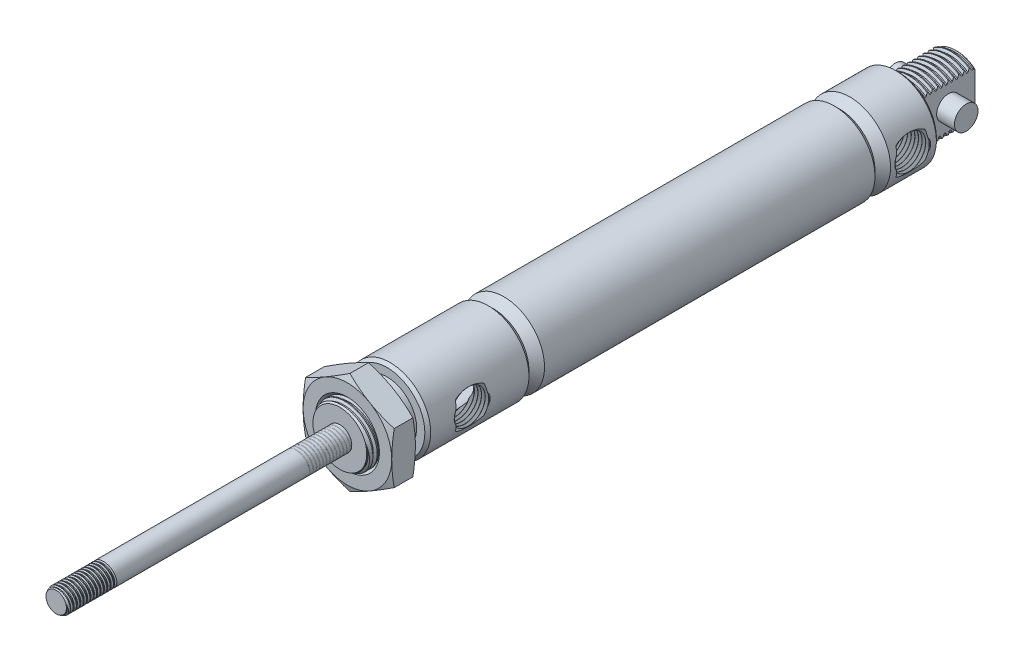
from build123d import *
from build123d.topology import SkipClean

# Parameters (mm, degrees)
SKETCH1_W            = 153.162
SKETCH1_H            = 10.922
SKETCH58_W           = 15.748
SKETCH58_H           = 2.9845
SKETCH59_OUTSIDE_W   = 55.094
SKETCH59_OUTSIDE_H   = 55.094
SKETCH59_OUTSIDE_W_2 = 9.525
SKETCH59_OUTSIDE_H_2 = 15.875
CUT_EXTRUDE3_DEPTH   = 15.748
CHAMFER1_SIZE        = 0.7874
SKETCH4_W            = 12.7
SKETCH4_H            = 7.9375
LPATTERN2_COUNT      = 2
LPATTERN2_PITCH      = 1.411111224
LPATTERN2_COL_COUNT  = 9
LPATTERN2_COL_PITCH  = 1.411111224
SKETCH53_W           = 2.286
SKETCH53_H           = 7.9375
LPATTERN5_COUNT      = 11
LPATTERN5_PITCH      = 1.411111224
SKETCH60_R           = 3.175
EXTRUDE2_DEPTH       = 9.525
LPATTERN3_COUNT      = 2
LPATTERN3_PITCH      = 0.907142966
LPATTERN3_COL_COUNT  = 14
LPATTERN3_COL_PITCH  = 0.907142966
LPATTERN4_COUNT      = 2
LPATTERN4_PITCH      = 63.5
SKETCH54_R           = 7.9375
EXTRUDE1_DEPTH       = 3.175


with BuildPart() as part:
    # Sketch1 → Revolve1 (revolve)
    with BuildSketch(Plane(origin=(0, 0, 0), x_dir=(0, 0, -1), z_dir=(1, 0, 0)), mode=Mode.PRIVATE) as revolve1_sk:
        with Locations((12.7, 5.461)):
            Rectangle(SKETCH1_W, SKETCH1_H)
    revolve(revolve1_sk.sketch.rotate(Axis((0, 0, -89.281), (0, 0, -1)), 270), axis=Axis((0, 0, -89.281), (0, 0, -1)))

    # Sketch58 → Cut-Revolve25 (revolve, cut)
    with BuildSketch(Plane(origin=(0, 0, 0), x_dir=(0, 0, -1), z_dir=(1, 0, 0)), mode=Mode.PRIVATE) as cut_revolve25_sk:
        with Locations((81.407, 9.42975)):
            Rectangle(SKETCH58_W, SKETCH58_H)
    revolve(cut_revolve25_sk.sketch.rotate(Axis((0, 0, -89.281), (0, 0, -1)), 270), axis=Axis((0, 0, -89.281), (0, 0, -1)), mode=Mode.SUBTRACT)

    # Sketch59 outside → Cut-Extrude3 (cut)
    with BuildSketch(Plane(origin=(0, 0, -89.281), x_dir=(-1, 0, 0), z_dir=(0, 0, -1))):
        Rectangle(SKETCH59_OUTSIDE_W, SKETCH59_OUTSIDE_H)
        Rectangle(SKETCH59_OUTSIDE_W_2, SKETCH59_OUTSIDE_H_2, mode=Mode.SUBTRACT)
    extrude(amount=-CUT_EXTRUDE3_DEPTH, mode=Mode.SUBTRACT)

    # Chamfer1
    chamfer1_edges = [part.edges().sort_by_distance(p)[0] for p in [
        (0, -7.9375, -89.281),
        (10.922, 0, 63.881),
        (10.922, 0, -73.533),
        (0, 7.9375, -89.281),
    ]]
    chamfer(chamfer1_edges, length=CHAMFER1_SIZE)



with BuildPart() as body_2:
    # Sketch4 → Revolve2 (revolve)
    with BuildSketch(Plane(origin=(0, 0, 0), x_dir=(0, 0, -1), z_dir=(1, 0, 0)), mode=Mode.PRIVATE) as revolve2_sk:
        with Locations((-70.231, 3.96875)):
            Rectangle(SKETCH4_W, SKETCH4_H)
    revolve(revolve2_sk.sketch.rotate(Axis((0, 0, 76.581), (0, 0, -1)), 90), axis=Axis((0, 0, 76.581), (0, 0, -1)))

    # Sketch5 → Cut-Revolve2 (revolve, cut)
    with BuildSketch(Plane(origin=(0, 0, 0), x_dir=(0, 0, -1), z_dir=(1, 0, 0)), mode=Mode.PRIVATE) as cut_revolve2_sk:
        Polygon((-76.40530384, 7.953117438), (-75.175430718, 8.062439502), (-75.547045629, 7.262609217), (-75.89843795, 7.231374341), align=None)
    cut_revolve2 = revolve(cut_revolve2_sk.sketch.rotate(Axis((0, -0.133549816, 76.581), (0, 0.08853979731145159, -0.9960726400680059)), 180), axis=Axis((0, -0.133549816, 76.581), (0, 0.08853979731145159, -0.9960726400680059)), mode=Mode.SUBTRACT)

    # Sketch6 → Cut-Revolve3 (revolve, cut)
    with BuildSketch(Plane(origin=(0, 0, 0), x_dir=(0, 0, -1), z_dir=(1, 0, 0)), mode=Mode.PRIVATE) as cut_revolve3_sk:
        Polygon((-76.581, 7.231374341), (-75.357954482, 7.9375), (-76.581, 7.9375), align=None)
    revolve(cut_revolve3_sk.sketch.rotate(Axis((0, 0, 0), (0, 0, 1)), 270), axis=Axis((0, 0, 0), (0, 0, 1)), mode=Mode.SUBTRACT)

    # LPattern2: Cut-Revolve2 ×2
    with Locations(*[(0, 0, i * LPATTERN2_PITCH) for i in range(1, LPATTERN2_COUNT)]):
        add(cut_revolve2, mode=Mode.SUBTRACT)

    # LPattern2 col: Cut-Revolve2 ×9
    with Locations(*[(0, 0, -i * LPATTERN2_COL_PITCH) for i in range(1, LPATTERN2_COL_COUNT)]):
        add(cut_revolve2, mode=Mode.SUBTRACT)


with BuildPart() as part_1:
    with SkipClean():  # the faces are left unmerged after this step: merging them gives an invalid solid
        add(part.part)

        add(body_2.part)  # Revolve4 merges body 2
        # Sketch53 → Revolve4 (revolve)
        with BuildSketch(Plane(origin=(0, 0, 0), x_dir=(0, 0, -1), z_dir=(1, 0, 0)), mode=Mode.PRIVATE) as revolve4_sk:
            with Locations((-65.024, 3.96875)):
                Rectangle(SKETCH53_W, SKETCH53_H)
        revolve(revolve4_sk.sketch.rotate(Axis((0, 0, 63.881), (0, 0, 1)), 125.383849969), axis=Axis((0, 0, 63.881), (0, 0, 1)))

    # Sketch62 → Cut-Revolve26 (revolve, cut)
    with SkipClean():  # the faces are left unmerged after this step: merging them gives an invalid solid
        with BuildSketch(Plane(origin=(0, 0, 0), x_dir=(0, 0, -1), z_dir=(1, 0, 0))):
            Polygon((73.70869616, 7.953117438), (74.938569282, 8.062439502), (74.566954371, 7.262609217), (74.21556205, 7.231374341), align=None)
        cut_revolve26 = revolve(axis=Axis((0, -0.133549816, -73.533), (0, 0.08853979731145115, -0.9960726400680059)), mode=Mode.SUBTRACT)

    # LPattern5: Cut-Revolve26 ×11
    with SkipClean():  # the faces are left unmerged after this step: merging them gives an invalid solid
        with Locations(*[(0, 0, -i * LPATTERN5_PITCH) for i in range(1, LPATTERN5_COUNT)]):
            add(cut_revolve26, mode=Mode.SUBTRACT)

    # Sketch60 → Extrude2 (add, symmetric)
    with SkipClean():  # the faces are left unmerged after this step: merging them gives an invalid solid
        with BuildSketch(Plane(origin=(0, 0, 0), x_dir=(0, 0, -1), z_dir=(1, 0, 0))):
            with Locations(Location((82.169, 0, 0), (0, 0, 180))):
                Circle(SKETCH60_R)
        extrude(amount=EXTRUDE2_DEPTH, both=True)

    # Sketch7 → Cut-Revolve5 (revolve, cut)
    with SkipClean():  # the faces are left unmerged after this step: merging them gives an invalid solid
        with BuildSketch(Plane(origin=(0, 0, 0), x_dir=(0, 0, -1), z_dir=(1, 0, 0)), mode=Mode.PRIVATE) as cut_revolve5_sk:
            Polygon((-76.581, 3.2004), (-60.706, 3.2004), (-60.706, 6.3627), (-18.542, 6.3627), (-18.542, 9.525), (-12.192, 9.525), (51.308, 9.525), (51.308, 0), (-76.581, 0), align=None)
            Polygon((56.261, 10.922), (57.658, 9.525), (57.658, 8.128), (60.452, 10.922), align=None)
            Polygon((-36.703, 10.922), (-35.306, 9.525), (-35.306, 8.128), (-32.512, 10.922), align=None)
        revolve(cut_revolve5_sk.sketch.rotate(Axis((0, 0, -51.308), (0, 0, -1)), 180), axis=Axis((0, 0, -51.308), (0, 0, -1)), mode=Mode.SUBTRACT)

    # Sketch13 → Cut-Revolve22 (revolve, cut)
    with SkipClean():  # the faces are left unmerged after this step: merging them gives an invalid solid
        with BuildSketch(Plane(origin=(-356.431898312, -1.751719437, -66.421), x_dir=(1, 0, 0), z_dir=(0, 0, 1))):
            Polygon((355.923898312, 1.751719437), (355.923898312, 5.954267841), (355.940851644, 5.985872426), (356.351637466, 6.751663784), (356.387484506, 6.75278406), (356.845286365, 6.014137423), (356.881133404, 6.015257699), (357.291919226, 6.781049057), (357.327766266, 6.782169333), (357.785568125, 6.043522697), (357.821415164, 6.044642973), (358.232200986, 6.810434331), (358.268048026, 6.811554607), (358.725849885, 6.07290797), (358.761696925, 6.074028246), (359.172482747, 6.839819604), (359.208329786, 6.84093988), (359.666131645, 6.102293244), (359.701978685, 6.10341352), (360.112764507, 6.869204878), (360.148611546, 6.870325154), (360.606413405, 6.131678517), (360.642260445, 6.132798793), (361.053046267, 6.898590151), (361.088893307, 6.899710427), (361.546695166, 6.161063791), (361.582542205, 6.162184066), (361.993328027, 6.927975424), (362.029175067, 6.9290957), (362.486976926, 6.190449064), (362.522823965, 6.19156934), (362.933609788, 6.957360698), (362.969456827, 6.958480974), (363.427258686, 6.219834337), (363.463105726, 6.220954613), (363.873891548, 6.986745971), (363.909738587, 6.987866247), (364.367540446, 6.249219611), (364.403387486, 6.250339887), (364.814173308, 7.016131245), (364.850020348, 7.017251521), (365.307822206, 6.278604884), (365.343669246, 6.27972516), (365.754455068, 7.045516518), (365.790302108, 7.046636794), (366.248103967, 6.307990158), (366.283951006, 6.309110434), (366.694736828, 7.074901792), (366.730583868, 7.076022068), (367.188385727, 6.337375431), (367.224232766, 6.338495707), (367.635018589, 7.104287065), (367.670865628, 7.105407341), (368.128667487, 6.366760705), (368.164514527, 6.367880981), (368.575300349, 7.133672339), (368.611147388, 7.134792615), (369.068949247, 6.396145978), (369.104796287, 6.397266254), (369.515582109, 7.163057612), (369.551429149, 7.164177888), (370.009231008, 6.425531252), (370.045078047, 6.426651528), (370.045078047, 1.751719437), align=None)
        revolve(axis=Axis((-0.508, 0, -66.421), (-1, 0, 0)), mode=Mode.SUBTRACT)

    # Sketch64 → Cut-Revolve27 (revolve, cut)
    with SkipClean():  # the faces are left unmerged after this step: merging them gives an invalid solid
        with BuildSketch(Plane(origin=(-356.431898312, -1.751719437, 51.943), x_dir=(1, 0, 0), z_dir=(0, 0, 1)), mode=Mode.PRIVATE) as cut_revolve27_sk:
            Polygon((355.923898312, 1.751719437), (355.923898312, 5.954267873), (355.949328308, 6.001674747), (356.343160766, 6.735861461), (356.396931321, 6.737541875), (356.835839438, 6.029379604), (356.889609993, 6.031060018), (357.283442451, 6.765246732), (357.337213006, 6.766927146), (357.776121123, 6.058764875), (357.829891678, 6.060445289), (358.223724136, 6.794632004), (358.277494691, 6.796312417), (358.716402808, 6.088150147), (358.770173363, 6.08983056), (359.164005821, 6.824017275), (359.217776376, 6.825697688), (359.656684493, 6.117535418), (359.710455048, 6.119215831), (360.104287506, 6.853402546), (360.158058061, 6.85508296), (360.596966178, 6.146920689), (360.650736733, 6.148601103), (361.044569191, 6.882787817), (361.098339746, 6.884468231), (361.537247863, 6.17630596), (361.591018418, 6.177986374), (361.984850876, 6.912173088), (362.038621431, 6.913853502), (362.477529548, 6.205691231), (362.531300103, 6.207371645), (362.925132561, 6.941558359), (362.978903116, 6.943238773), (363.417811233, 6.235076502), (363.471581788, 6.236756916), (363.865414246, 6.97094363), (363.919184801, 6.972624044), (364.358092918, 6.264461773), (364.411863473, 6.266142187), (364.805695931, 7.000328901), (364.859466486, 7.002009315), (365.298374603, 6.293847044), (365.352145158, 6.295527458), (365.745977616, 7.029714172), (365.799748171, 7.031394586), (366.238656288, 6.323232315), (366.292426843, 6.324912729), (366.686259301, 7.059099443), (366.740029856, 7.060779857), (367.178937973, 6.352617586), (367.232708528, 6.354298), (367.626540986, 7.088484715), (367.680311541, 7.090165128), (368.119219658, 6.382002857), (368.172990213, 6.383683271), (368.566822671, 7.117869986), (368.620593226, 7.119550399), (369.059501343, 6.411388129), (369.113271898, 6.413068542), (369.507104356, 7.147255257), (369.560874911, 7.148935671), (369.999783028, 6.4407734), (370.053553583, 6.442453814), (370.053553583, 1.751719437), align=None)
        revolve(cut_revolve27_sk.sketch.rotate(Axis((-0.508, 0, 51.943), (1, 0, 0)), 90), axis=Axis((-0.508, 0, 51.943), (1, 0, 0)), mode=Mode.SUBTRACT)


with BuildPart() as body_2_2:
    # Sketch8 → Revolve3 (revolve)
    with BuildSketch(Plane(origin=(0, 0, 0), x_dir=(0, 0, -1), z_dir=(1, 0, 0)), mode=Mode.PRIVATE) as revolve3_sk:
        Polygon((44.958, 9.4742), (51.308, 9.4742), (51.308, 0), (-89.281, 0), (-89.281, 3.175), (44.958, 3.175), align=None)
    revolve(revolve3_sk.sketch.rotate(Axis((0, 0, -51.308), (0, 0, 1)), 125.383849969), axis=Axis((0, 0, -51.308), (0, 0, 1)))

    # Sketch10 → Cut-Revolve6 (revolve, cut)
    with BuildSketch(Plane(origin=(0, 0, 0), x_dir=(0, 0, -1), z_dir=(1, 0, 0)), mode=Mode.PRIVATE) as cut_revolve6_sk:
        Polygon((-89.168746785, 3.191036175), (-88.382974282, 3.303289404), (-88.594168642, 2.777128287), (-88.818675072, 2.745055936), align=None)
    cut_revolve6 = revolve(cut_revolve6_sk.sketch.rotate(Axis((0, -0.138431434, 89.281), (0, 0.14142137286846326, -0.9899494912852873)), 180), axis=Axis((0, -0.138431434, 89.281), (0, 0.14142137286846326, -0.9899494912852873)), mode=Mode.SUBTRACT)

    # Sketch11 → Cut-Revolve7 (revolve, cut)
    with BuildSketch(Plane(origin=(0, 0, 0), x_dir=(0, 0, -1), z_dir=(1, 0, 0)), mode=Mode.PRIVATE) as cut_revolve7_sk:
        Polygon((-89.281, 3.175), (-88.536315037, 3.175), (-89.281, 2.745055936), align=None)
    revolve(cut_revolve7_sk.sketch.rotate(Axis((0, 0, 0), (0, 0, 1)), 125.383849969), axis=Axis((0, 0, 0), (0, 0, 1)), mode=Mode.SUBTRACT)

    # LPattern3: Cut-Revolve6 ×2
    with Locations(*[(0, 0, i * LPATTERN3_PITCH) for i in range(1, LPATTERN3_COUNT)]):
        add(cut_revolve6, mode=Mode.SUBTRACT)

    # LPattern3 col: Cut-Revolve6 ×14
    with Locations(*[(0, 0, -i * LPATTERN3_COL_PITCH) for i in range(1, LPATTERN3_COL_COUNT)]):
        add(cut_revolve6, mode=Mode.SUBTRACT)


with BuildPart() as lpattern4_1:
    # LPattern4: pattern copy
    add(body_2_2.part.moved(Location(Vector(0, 0, 1) * (1 * LPATTERN4_PITCH))))


with BuildPart() as body_4:
    # Sketch54 → Extrude1 (new, symmetric)
    with BuildSketch(Plane.XY.offset(71.374)):
        Polygon((0, 13.748153285), (-11.90625, 6.874076643), (-11.90625, -6.874076643), (0, -13.748153285), (11.90625, -6.874076643), (11.90625, 6.874076643), align=None)
        Circle(SKETCH54_R, mode=Mode.SUBTRACT)
    extrude(amount=EXTRUDE1_DEPTH, both=True)

    # Sketch55 → Cut-Revolve24 (revolve, cut)
    with BuildSketch(Plane(origin=(0, 0, 0), x_dir=(0, 0, -1), z_dir=(1, 0, 0)), mode=Mode.PRIVATE) as cut_revolve24_sk:
        Polygon((-73.87860203, 13.748153285), (-74.549, 13.748153285), (-74.549, 11.90625), align=None)
        Polygon((-68.86939797, 13.748153285), (-68.199, 13.748153285), (-68.199, 11.90625), align=None)
        Polygon((-74.549, 8.60789797), (-74.549, 7.9375), (-73.87860203, 7.9375), align=None)
        Polygon((-68.199, 8.60789797), (-68.199, 7.9375), (-68.86939797, 7.9375), align=None)
    revolve(cut_revolve24_sk.sketch.rotate(Axis((0, 0, 0), (0, 0, 1)), 124.802032131), axis=Axis((0, 0, 0), (0, 0, 1)), mode=Mode.SUBTRACT)


solid = Compound([part_1.part, body_2_2.part, lpattern4_1.part, body_4.part])
